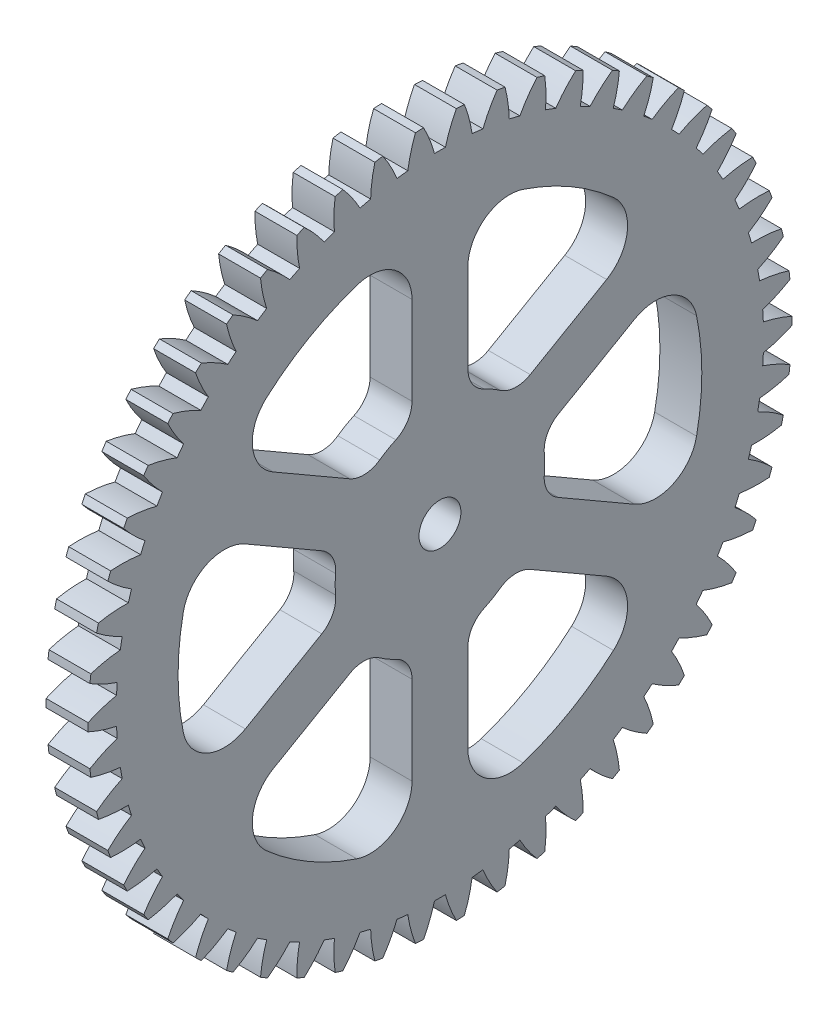
from build123d import *

# Parameters (mm, degrees)
BASPROSKE_W              = 3
BASPROSKE_H              = 25.2
TOOTHCUT_DEPTH           = 36.764227938
TEETHCUTS_COUNT          = 54
TEETHCUTS_ANGLE          = 353.333333333
SKETCH1_R                = 1.5
CUT_EXTRUDE1_DEPTH       = 36.744835465
CUT_EXTRUDE2_DEPTH       = 36.744835465
FILLET1_R                = 2
FILLET2_R                = 3
CIRPATTERN2_COUNT        = 6
FILLET1_OF_CIRPATTERN2_R = 2
FILLET2_OF_CIRPATTERN2_R = 3


with BuildPart() as part:
    # BasProSke → Base-Revolve (revolve)
    with BuildSketch(Plane(origin=(0, 0, 0), x_dir=(1, 0, 0), z_dir=(0, 1, 0)), mode=Mode.PRIVATE) as base_revolve_sk:
        with Locations((1.5, 12.6)):
            Rectangle(BASPROSKE_W, BASPROSKE_H)
    revolve(base_revolve_sk.sketch.rotate(Axis((-10, 0, 0), (1, 0, 0)), 180), axis=Axis((-10, 0, 0), (1, 0, 0)))

    # TooCutSke → ToothCut (cut, through all)
    with BuildSketch(Plane(origin=(0, 0, 0), x_dir=(0, 0, -1), z_dir=(1, 0, 0))):
        with BuildLine():
            ThreePointArc((0.390547572, 23.17070885), (0, 23.174), (-0.390547572, 23.17070885))
            ThreePointArc((-0.390547572, 23.17070885), (-0.733677002, 24.206486815), (-1.19073407, 25.197280757))
            ThreePointArc((-1.19073407, 25.197280757), (0, 25.2254), (1.19073407, 25.197280757))
            ThreePointArc((1.19073407, 25.197280757), (0.733677002, 24.206486815), (0.390547572, 23.17070885))
        make_face()
    toothcut = extrude(amount=TOOTHCUT_DEPTH, mode=Mode.SUBTRACT)

    # TeethCuts: ToothCut ×54 about axis
    teethcuts_axis = Axis((-10, 0, 0), (1, 0, 0))
    for i in range(1, TEETHCUTS_COUNT):
        add(toothcut.rotate(teethcuts_axis, i * TEETHCUTS_ANGLE / (TEETHCUTS_COUNT - 1)), mode=Mode.SUBTRACT)

    # Sketch1 → Cut-Extrude1 (cut, through all)
    with BuildSketch(Plane(origin=(3, 0, 0), x_dir=(0, 0, -1), z_dir=(1, 0, 0))):
        Circle(SKETCH1_R)
    extrude(amount=-CUT_EXTRUDE1_DEPTH, mode=Mode.SUBTRACT)

    # Sketch2 → Cut-Extrude2 (cut, through all)
    with BuildSketch(Plane(origin=(3, 0, 0), x_dir=(0, 0, -1), z_dir=(1, 0, 0))):
        with BuildLine():
            Line((-2, 18.643028188), (-2, 7.228416147))
            ThreePointArc((-2, 7.228416147), (-3.75, 6.495190528), (-5.259992013, 5.346258881))
            Line((-5.259992013, 5.346258881), (-15.145336014, 11.053564901))
            ThreePointArc((-15.145336014, 11.053564901), (-9.375, 16.237976321), (-2, 18.643028188))
        make_face()
    cut_extrude2 = extrude(amount=-CUT_EXTRUDE2_DEPTH, mode=Mode.SUBTRACT)

    # Fillet1
    fillet1_edges = [part.edges().sort_by_distance(p)[0] for p in [
        (1.5, 7.228416147, 2),
        (1.5, 5.346258881, 5.259992013),
    ]]
    fillet(fillet1_edges, radius=FILLET1_R)

    # Fillet2
    fillet2_edges = [part.edges().sort_by_distance(p)[0] for p in [
        (1.5, 11.053564901, 15.145336014),
        (1.5, 18.643028188, 2),
    ]]
    fillet(fillet2_edges, radius=FILLET2_R)

    # CirPattern2: Cut-Extrude2 ×6 about axis
    cirpattern2_axis = Axis((0, 0, 0), (1, 0, 0))
    for i in range(1, CIRPATTERN2_COUNT):
        add(cut_extrude2.rotate(cirpattern2_axis, i * 360 / CIRPATTERN2_COUNT), mode=Mode.SUBTRACT)

    # Fillet1 of CirPattern2
    fillet1_of_cirpattern2_edges = [part.edges().sort_by_distance(p)[0] for p in [
        (1.5, 1.882157266, 7.259992013),
        (1.5, -1.882157266, 7.259992013),
        (1.5, -5.346258881, 5.259992013),
        (1.5, -7.228416147, 2),
        (1.5, -7.228416147, -2),
        (1.5, -5.346258881, -5.259992013),
        (1.5, -1.882157266, -7.259992013),
        (1.5, 1.882157266, -7.259992013),
        (1.5, 5.346258881, -5.259992013),
        (1.5, 7.228416147, -2),
    ]]
    fillet(fillet1_of_cirpattern2_edges, radius=FILLET1_OF_CIRPATTERN2_R)

    # Fillet2 of CirPattern2
    fillet2_of_cirpattern2_edges = [part.edges().sort_by_distance(p)[0] for p in [
        (1.5, -7.589463286, 17.145336014),
        (1.5, 7.589463286, 17.145336014),
        (1.5, -18.643028188, 2),
        (1.5, -11.053564901, 15.145336014),
        (1.5, -11.053564901, -15.145336014),
        (1.5, -18.643028188, -2),
        (1.5, 7.589463286, -17.145336014),
        (1.5, -7.589463286, -17.145336014),
        (1.5, 18.643028188, -2),
        (1.5, 11.053564901, -15.145336014),
    ]]
    fillet(fillet2_of_cirpattern2_edges, radius=FILLET2_OF_CIRPATTERN2_R)


solid = part.part
